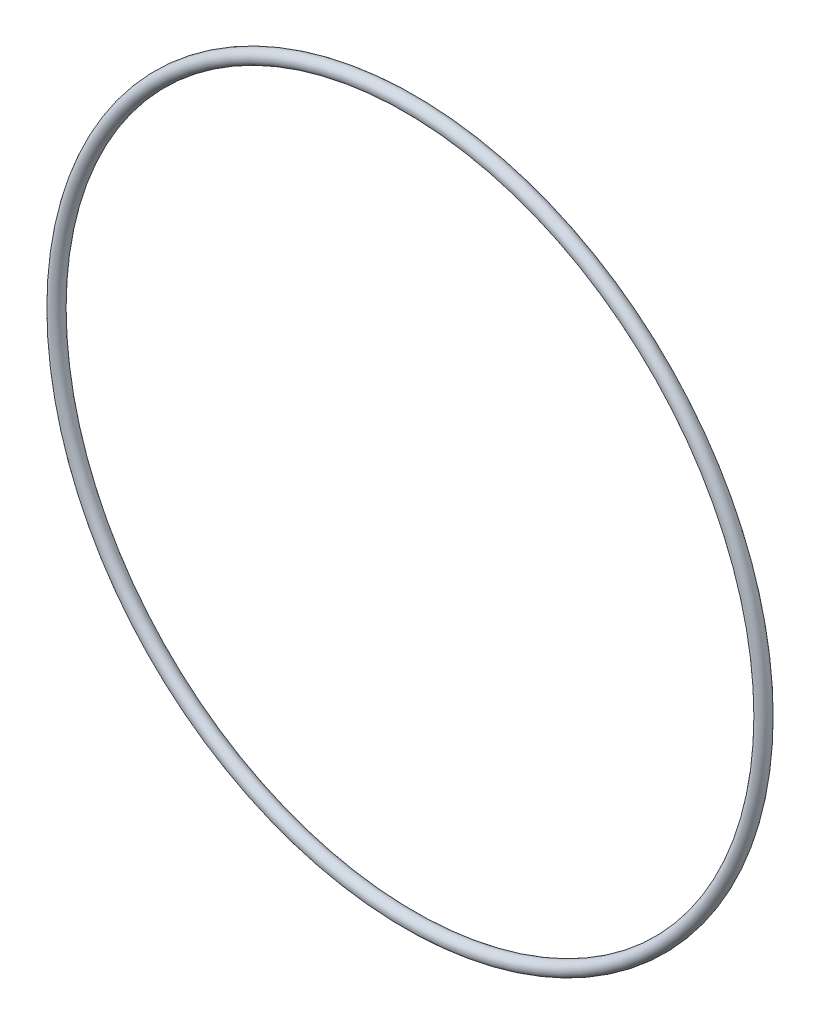
from build123d import *

# Parameters (mm, degrees)
SKETCH1_R = 1.3081


with BuildPart() as part:
    # Sketch1 → Revolve1 (revolve)
    with BuildSketch(Plane(origin=(0, 0, 0), x_dir=(0, -1, 0), z_dir=(1, 0, 0))):
        with Locations((67.818, 0)):
            Circle(SKETCH1_R)
    revolve(axis=Axis((0, 0, 1.3081), (0, 0, -1)))


solid = part.part
